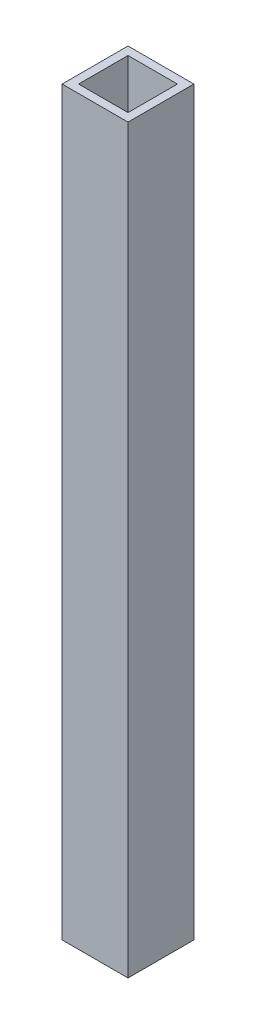
from build123d import *

# Parameters (mm, degrees)
SCHIZZO1_W                   = 40
SCHIZZO1_H                   = 40
SCHIZZO1_W_2                 = 30
SCHIZZO1_H_2                 = 30
ESTRUSIONE_ESTRUSIONE1_DEPTH = 225


with BuildPart() as part:
    # Schizzo1 → Estrusione-Estrusione1 (new body, symmetric)
    with BuildSketch(Plane(origin=(0, 0, 0), x_dir=(1, 0, 0), z_dir=(0, 1, 0))):
        Rectangle(SCHIZZO1_W, SCHIZZO1_H)
        Rectangle(SCHIZZO1_W_2, SCHIZZO1_H_2, mode=Mode.SUBTRACT)
    extrude(amount=ESTRUSIONE_ESTRUSIONE1_DEPTH, both=True)


solid = part.part
